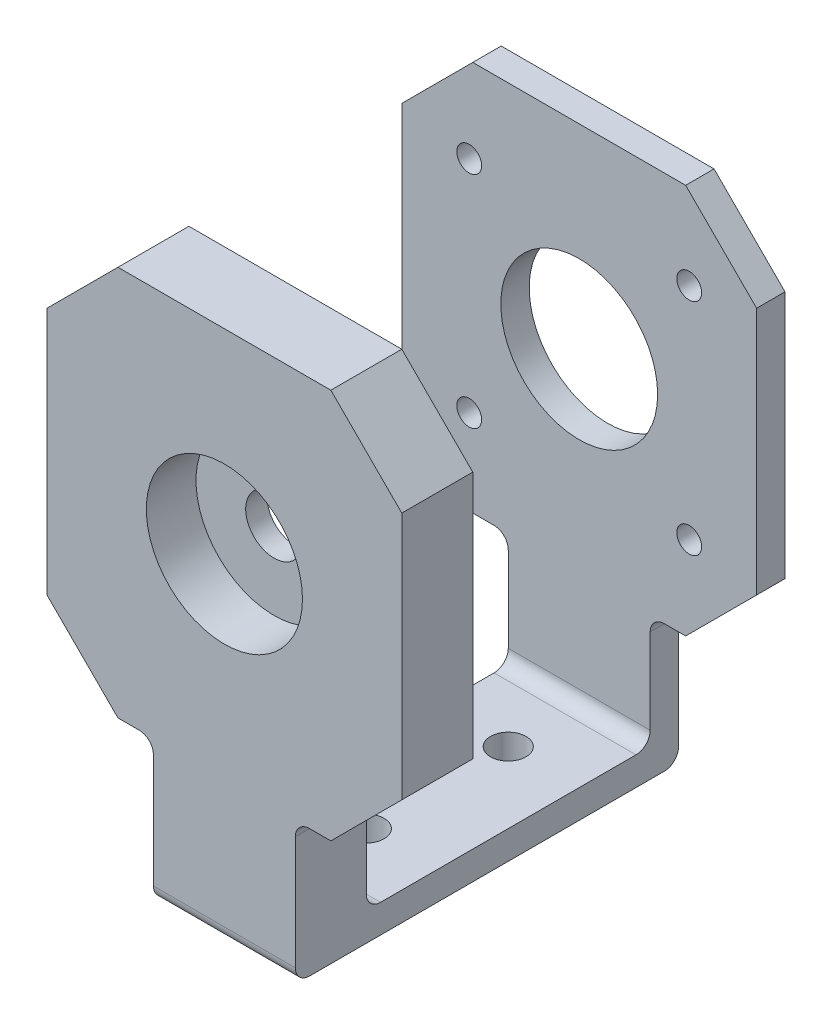
from build123d import *

# Parameters (mm, degrees)
SCHIZZO1_R                   = 1.75
SCHIZZO1_R_2                 = 11.05
ESTRUSIONE_ESTRUSIONE1_DEPTH = 4
SCHIZZO14_W                  = 20
SCHIZZO14_H                  = 4
ESTRUSIONE_ESTRUSIONE2_DEPTH = 40
ESTRUSIONE_ESTRUSIONE3_DEPTH = 10
SCHIZZO19_R                  = 11
TAGLIO_ESTRUSIONE1_DEPTH     = 7
SCHIZZO20_R                  = 4
TAGLIO_ESTRUSIONE2_DEPTH     = 7
SMUSSO1_SIZE                 = 10
RACCORDO1_R                  = 2
SCHIZZO21_R                  = 2.5
TAGLIO_ESTRUSIONE3_DEPTH     = 10


with BuildPart() as part:
    # Schizzo1 → Estrusione-Estrusione1 (new body)
    with BuildSketch(Plane.XY):
        Polygon((-25, -27.5), (-10, -27.5), (-10, -47.5), (10, -47.5), (10, -27.5), (25, -27.5), (25, 27.5), (-25, 27.5), align=None)
        with Locations((-15.5, 15.5)):
            Circle(SCHIZZO1_R, mode=Mode.SUBTRACT)
        with Locations((15.5, 15.5)):
            Circle(SCHIZZO1_R, mode=Mode.SUBTRACT)
        with Locations((15.5, -15.5)):
            Circle(SCHIZZO1_R, mode=Mode.SUBTRACT)
        with Locations((-15.5, -15.5)):
            Circle(SCHIZZO1_R, mode=Mode.SUBTRACT)
        Circle(SCHIZZO1_R_2, mode=Mode.SUBTRACT)
    extrude(amount=ESTRUSIONE_ESTRUSIONE1_DEPTH)

    # Schizzo14 → Estrusione-Estrusione2 (add)
    with BuildSketch(Plane.XY.offset(4)):
        with Locations((0, -45.5)):
            Rectangle(SCHIZZO14_W, SCHIZZO14_H)
    extrude(amount=ESTRUSIONE_ESTRUSIONE2_DEPTH)

    # Schizzo18 → Estrusione-Estrusione3 (add)
    with BuildSketch(Plane.XY.offset(44)):
        Polygon((-25, -27.5), (-10, -27.5), (-10, -47.5), (10, -47.5), (10, -27.5), (25, -27.5), (25, 27.5), (-25, 27.5), align=None)
    extrude(amount=ESTRUSIONE_ESTRUSIONE3_DEPTH)

    # Schizzo19 → Taglio-Estrusione1 (cut)
    with BuildSketch(Plane.XY.offset(54)):
        Circle(SCHIZZO19_R)
    extrude(amount=-TAGLIO_ESTRUSIONE1_DEPTH, mode=Mode.SUBTRACT)

    # Schizzo20 → Taglio-Estrusione2 (cut)
    with BuildSketch(Plane.XY.offset(47)):
        Circle(SCHIZZO20_R)
    extrude(amount=-TAGLIO_ESTRUSIONE2_DEPTH, mode=Mode.SUBTRACT)

    # Smusso1
    smusso1_edges = [part.edges().sort_by_distance(p)[0] for p in [
        (25, -27.5, 2),
        (-25, -27.5, 2),
        (-25, 27.5, 2),
        (25, 27.5, 2),
        (25, -27.5, 49),
        (25, 27.5, 49),
        (-25, 27.5, 49),
        (-25, -27.5, 49),
    ]]
    chamfer(smusso1_edges, length=SMUSSO1_SIZE)

    # Raccordo1
    raccordo1_edges = [part.edges().sort_by_distance(p)[0] for p in [
        (10, -27.5, 2),
        (-10, -27.5, 2),
        (0, -43.5, 4),
        (0, -43.5, 44),
        (-10, -27.5, 49),
        (10, -27.5, 49),
        (0, -47.5, 54),
        (0, -47.5, 0),
    ]]
    fillet(raccordo1_edges, radius=RACCORDO1_R)

    # Schizzo21 → Taglio-Estrusione3 (cut)
    with BuildSketch(Plane(origin=(0, -43.5, 0), x_dir=(1, 0, 0), z_dir=(0, 1, 0))):
        with Locations((0, -14)):
            Circle(SCHIZZO21_R)
        with Locations((0, -34)):
            Circle(SCHIZZO21_R)
    extrude(amount=-TAGLIO_ESTRUSIONE3_DEPTH, mode=Mode.SUBTRACT)


solid = part.part
